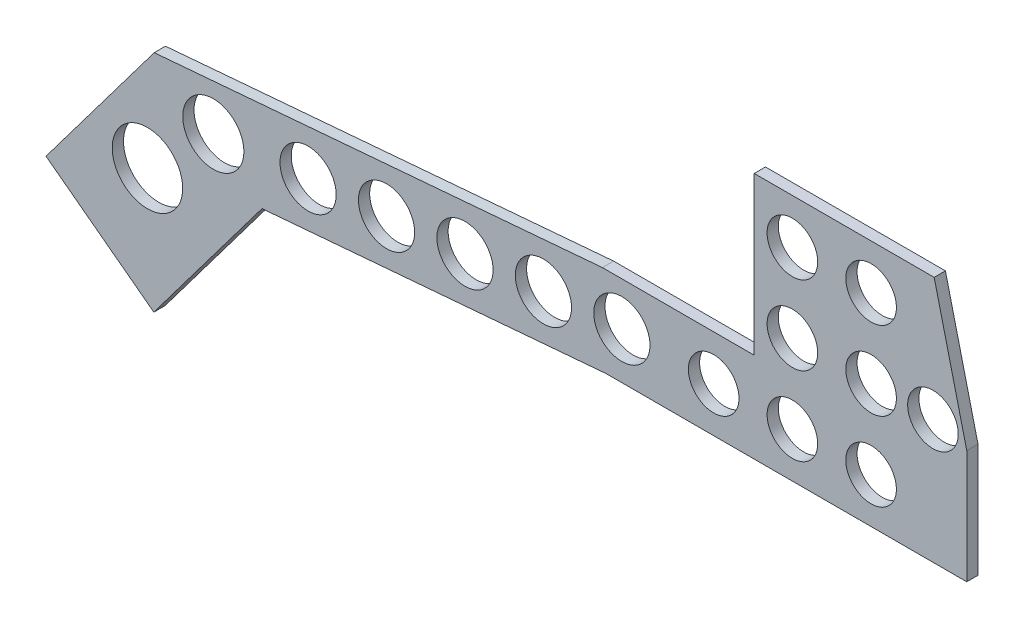
from build123d import *

# Parameters (mm, degrees)
BOSS_EXTRUDE1_DEPTH = 3.175
SKETCH2_R           = 9.946432709
SKETCH2_R_2         = 8.628774031
SKETCH2_R_3         = 7.9375
SKETCH2_R_4         = 7.14375
CUT_EXTRUDE1_DEPTH  = 4.175


with BuildPart() as part:
    # Sketch1 → Boss-Extrude1 (new body)
    with BuildSketch(Plane.XY):
        Polygon((0, 0), (50.8, 0), (60, -37.754085603), (60, -69.85), (-41.787887726, -69.85), (-138.966701689, -78.087543548), (-169.514196693, -118.67683461), (-199.95616499, -95.766213357), (-169.408669986, -55.176922294), (-42.8625, -44.45), (0, -44.45), align=None)
    extrude(amount=BOSS_EXTRUDE1_DEPTH)

    # Sketch2 → Cut-Extrude1 (cut, through all)
    with BuildSketch(Plane.XY.offset(3.175)):
        with Locations((-171.31481468, -84.35191449)):
            Circle(SKETCH2_R)
        with Locations((-152.715034722, -66.714192116)):
            Circle(SKETCH2_R_2)
        with Locations((-125.957448531, -64.239244165)):
            Circle(SKETCH2_R_3)
        with Locations((-103.811868784, -62.362032763)):
            Circle(SKETCH2_R_3)
        with Locations((-81.666289037, -60.484821362)):
            Circle(SKETCH2_R_3)
        with Locations((-59.52070929, -58.60760996)):
            Circle(SKETCH2_R_3)
        with Locations((-37.375129542, -56.730398559)):
            Circle(SKETCH2_R_3)
        with Locations((-11.455180712, -57.15)):
            Circle(SKETCH2_R_4)
        with Locations((10.769819288, -57.15)):
            Circle(SKETCH2_R_4)
        with Locations((32.994819288, -57.15)):
            Circle(SKETCH2_R_4)
        with Locations((10.769819288, -34.925)):
            Circle(SKETCH2_R_4)
        with Locations((32.994819288, -34.925)):
            Circle(SKETCH2_R_4)
        with Locations((10.769819288, -12.7)):
            Circle(SKETCH2_R_4)
        with Locations((32.994819288, -12.7)):
            Circle(SKETCH2_R_4)
        with Locations((-11.455180712, -34.925)):
            Circle(SKETCH2_R_4)
        with Locations((-11.455180712, -12.7)):
            Circle(SKETCH2_R_4)
        with Locations((50.457319288, -34.925)):
            Circle(SKETCH2_R_4)
    extrude(amount=-CUT_EXTRUDE1_DEPTH, mode=Mode.SUBTRACT)


solid = part.part
